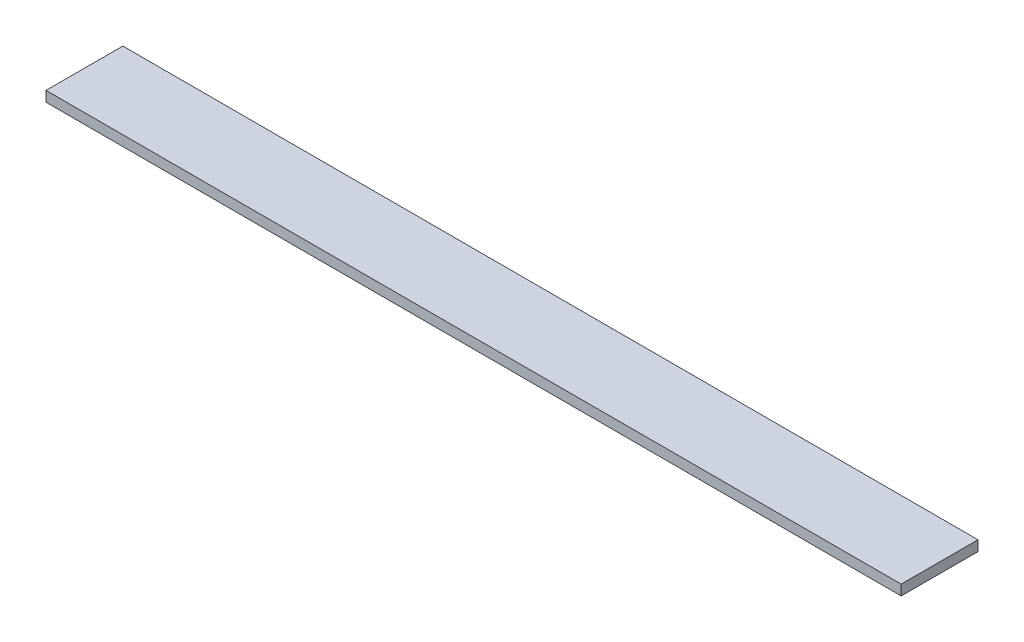
from build123d import *

# Parameters (mm, degrees)
SKETCH_1_W      = 30
SKETCH_1_H      = 4
EXTRUDE_1_DEPTH = 334


with BuildPart() as part:
    # Эскиз1 → Бобышка-Вытянуть1 (new body)
    with BuildSketch(Plane(origin=(0, 0, 0), x_dir=(0, 0, -1), z_dir=(1, 0, 0))):
        Rectangle(SKETCH_1_W, SKETCH_1_H)
    extrude(amount=EXTRUDE_1_DEPTH)


solid = part.part
